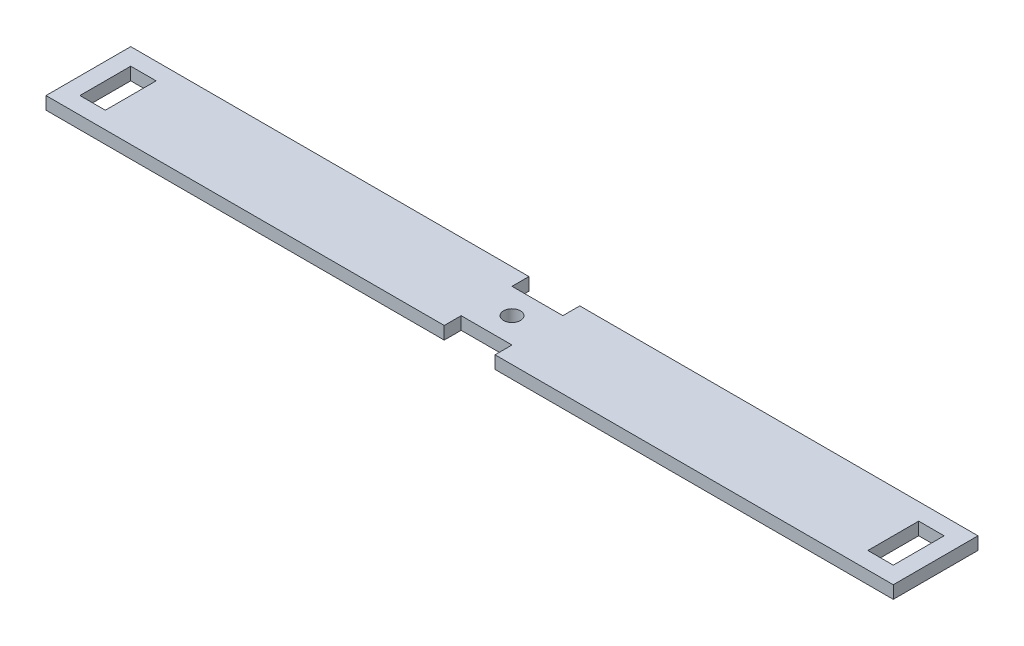
from build123d import *

# Parameters (mm, degrees)
SKETCH1_W           = 100
SKETCH1_H           = 10
BOSS_EXTRUDE1_DEPTH = 1.5
SKETCH2_R           = 1
CUT_EXTRUDE2_DEPTH  = 2
SKETCH5_W           = 6
SKETCH5_H           = 2
SKETCH5_W_2         = 3
SKETCH5_H_2         = 6
CUT_EXTRUDE4_DEPTH  = 2


with BuildPart() as part:
    # Sketch1 → Boss-Extrude1 (new body)
    with BuildSketch(Plane(origin=(0, 0, 0), x_dir=(1, 0, 0), z_dir=(0, 1, 0))):
        with Locations((40.170187286, 0.880693734)):
            Rectangle(SKETCH1_W, SKETCH1_H)
    extrude(amount=BOSS_EXTRUDE1_DEPTH)

    # Sketch2 → Cut-Extrude2 (cut)
    with BuildSketch(Plane(origin=(0, 1.5, 0), x_dir=(1, 0, 0), z_dir=(0, 1, 0))):
        with Locations((40.170187286, 0.880693734)):
            Circle(SKETCH2_R)
    extrude(amount=-CUT_EXTRUDE2_DEPTH, mode=Mode.SUBTRACT)

    # Sketch5 → Cut-Extrude4 (cut)
    with BuildSketch(Plane(origin=(0, 1.5, 0), x_dir=(1, 0, 0), z_dir=(0, 1, 0))):
        with Locations((40.170187286, 4.880693734)):
            Rectangle(SKETCH5_W, SKETCH5_H)
        with Locations((40.170187286, -3.119306266)):
            Rectangle(SKETCH5_W, SKETCH5_H)
        with Locations((-6.329812714, 0.880693734)):
            Rectangle(SKETCH5_W_2, SKETCH5_H_2)
        with Locations((86.670187286, 0.880693734)):
            Rectangle(SKETCH5_W_2, SKETCH5_H_2)
    extrude(amount=-CUT_EXTRUDE4_DEPTH, mode=Mode.SUBTRACT)


solid = part.part
